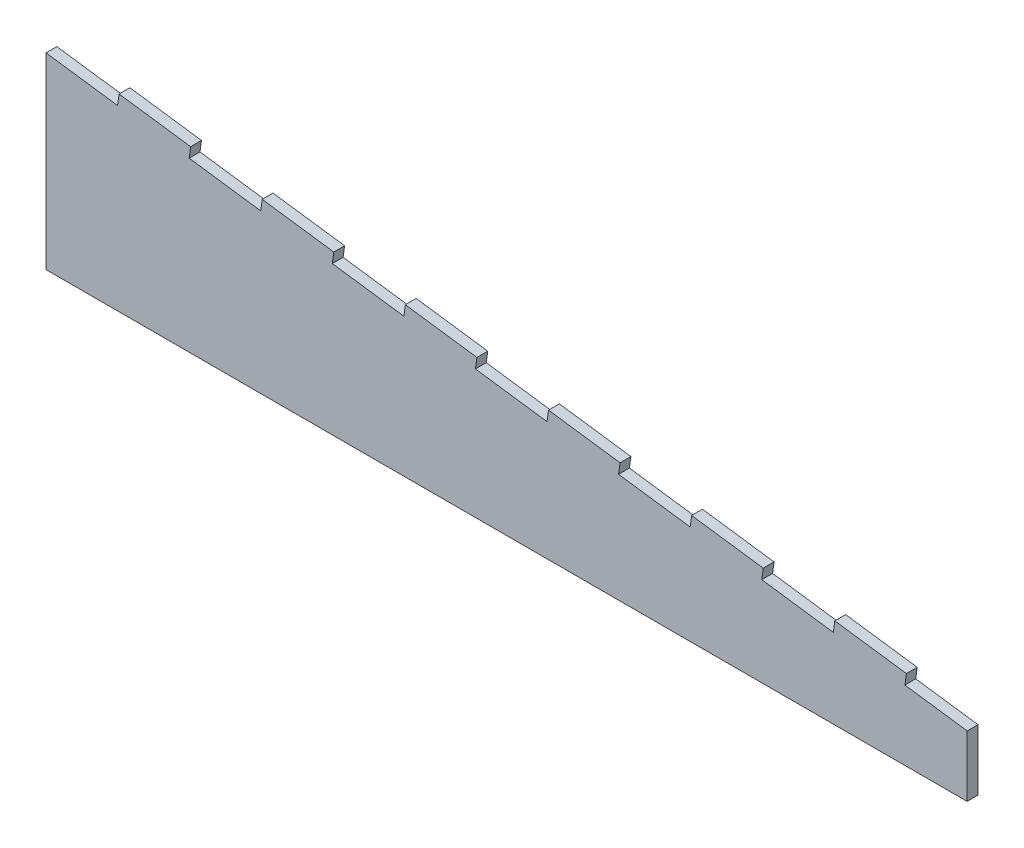
from build123d import *

# Parameters (mm, degrees)
BOSS_EXTRU_1_DEPTH      = 3
ENL_V_MAT_EXTRU_1_DEPTH = 4


with BuildPart() as part:
    # Esquisse1 → Boss.-Extru.1 (new body)
    with BuildSketch(Plane.XY):
        Polygon((0, 0), (-255, 0), (-255, 55), (0, 19.9375), align=None)
    extrude(amount=BOSS_EXTRU_1_DEPTH)

    # Esquisse2 → Enlèv. mat.-Extru.1 (cut, through all)
    with BuildSketch(Plane.XY.offset(3)):
        Polygon((-235.186423203, 49.247406605), (-234.777768182, 52.219443125), (-255, 55), (-255, 51.971773415), align=None)
        Polygon((-195.150614588, 46.770709506), (-214.964191385, 49.495076315), (-215.372846406, 46.523039796), (-195.559269609, 43.798672986), align=None)
        Polygon((-155.523460994, 41.321975887), (-175.337037791, 44.046342696), (-175.745692812, 41.074306177), (-155.932116015, 38.349939367), align=None)
        Polygon((-115.8963074, 35.873242268), (-135.709884197, 38.597609077), (-136.118539219, 35.625572558), (-116.304962422, 32.901205748), align=None)
        Polygon((-76.269153806, 30.424508648), (-96.082730603, 33.148875458), (-96.491385625, 30.176838938), (-76.677808828, 27.452472129), align=None)
        Polygon((-36.642000213, 24.975775029), (-56.45557701, 27.700141839), (-56.864232031, 24.728105319), (-37.050655234, 22.00373851), align=None)
        Polygon((0, 19.9375), (-16.828423416, 22.25140822), (-17.237078437, 19.2793717), (0, 16.909273415), align=None)
    extrude(amount=-ENL_V_MAT_EXTRU_1_DEPTH, mode=Mode.SUBTRACT)


solid = part.part
